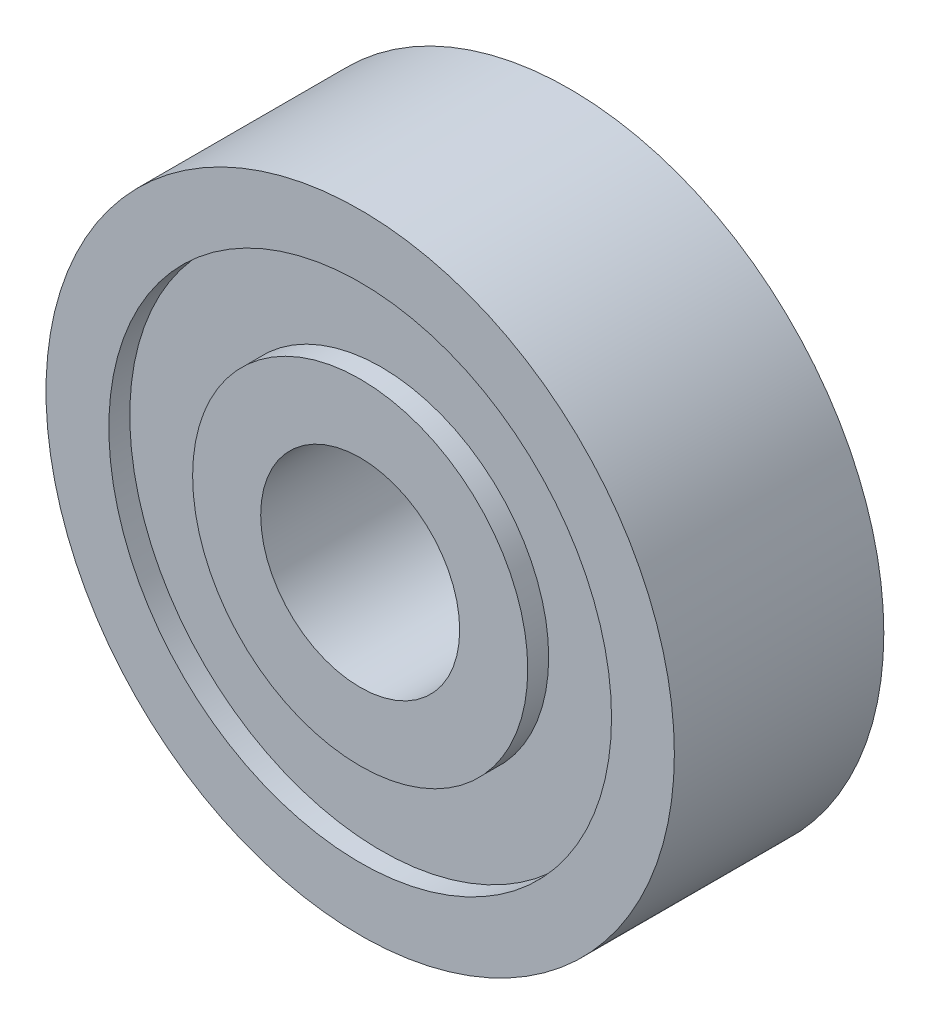
from build123d import *

# Parameters (mm, degrees)
SKETCH1_R           = 15
SKETCH1_R_2         = 4.75
BOSS_EXTRUDE1_DEPTH = 10
SKETCH2_R           = 12
SKETCH2_R_2         = 8
CUT_EXTRUDE1_DEPTH  = 1
SKETCH4_R           = 12
SKETCH4_R_2         = 8
CUT_EXTRUDE2_DEPTH  = 1


with BuildPart() as part:
    # Sketch1 → Boss-Extrude1 (new body)
    with BuildSketch(Plane.XY):
        Circle(SKETCH1_R)
        Circle(SKETCH1_R_2, mode=Mode.SUBTRACT)
    extrude(amount=BOSS_EXTRUDE1_DEPTH)

    # Sketch2 → Cut-Extrude1 (cut)
    with BuildSketch(Plane.XY):
        Circle(SKETCH2_R)
        Circle(SKETCH2_R_2, mode=Mode.SUBTRACT)
    extrude(amount=CUT_EXTRUDE1_DEPTH, mode=Mode.SUBTRACT)

    # Sketch4 → Cut-Extrude2 (cut)
    with BuildSketch(Plane.XY.offset(10)):
        Circle(SKETCH4_R)
        Circle(SKETCH4_R_2, mode=Mode.SUBTRACT)
    extrude(amount=-CUT_EXTRUDE2_DEPTH, mode=Mode.SUBTRACT)


solid = part.part
